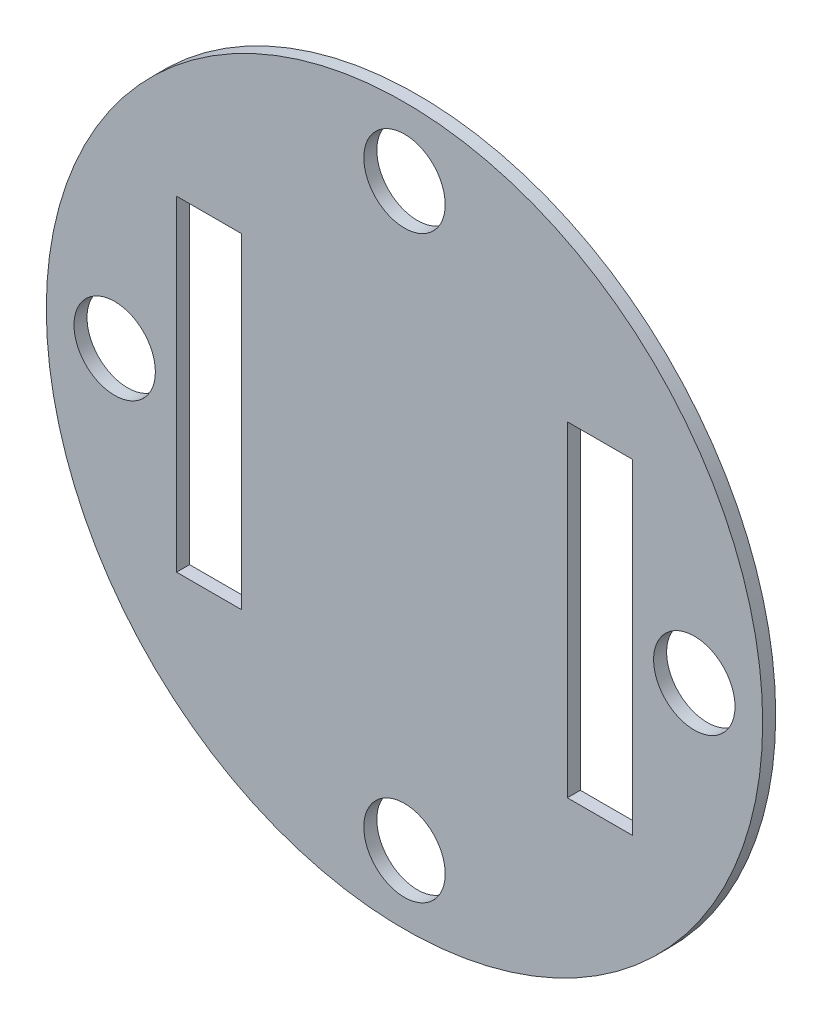
from build123d import *

# Parameters (mm, degrees)
SKETCH4_R           = 59
BOSS_EXTRUDE3_DEPTH = 2
SKETCH5_R           = 1.375
BOSS_EXTRUDE5_DEPTH = 7
SKETCH8_R           = 2.375
BOSS_EXTRUDE6_DEPTH = 2
BOSS_EXTRUDE7_DEPTH = 18
SKETCH10_R          = 7.5
CUT_EXTRUDE1_DEPTH  = 18
SKETCH12_R          = 57.5
CUT_EXTRUDE2_DEPTH  = 5
CUT_EXTRUDE3_DEPTH  = 5.5
SKETCH15_R          = 89.714021058
SKETCH15_R_2        = 57
CUT_EXTRUDE4_DEPTH  = 22
SKETCH16_R          = 62.462022857
CUT_EXTRUDE8_DEPTH  = 52
CUT_EXTRUDE9_DEPTH  = 52
SKETCH18_R          = 80.62246508
SKETCH18_R_2        = 55
CUT_EXTRUDE10_DEPTH = 10
SKETCH19_R          = 55
BOSS_EXTRUDE8_DEPTH = 2
SKETCH20_R          = 6.25
CUT_EXTRUDE11_DEPTH = 2
SKETCH21_W          = 10
SKETCH21_H          = 50
CUT_EXTRUDE12_DEPTH = 3
SKETCH22_R          = 40.394642533
CUT_EXTRUDE13_DEPTH = 10


with BuildPart() as part:
    # Sketch4 → Boss-Extrude3 (new body)
    with BuildSketch(Plane.XY):
        Circle(SKETCH4_R)
    extrude(amount=BOSS_EXTRUDE3_DEPTH)

    # Sketch5 → Boss-Extrude5 (add)
    with BuildSketch(Plane.XY.offset(2)):
        with Locations((-22.5, 27.5)):
            Circle(SKETCH5_R)
        with Locations((22.5, 27.5)):
            Circle(SKETCH5_R)
        with Locations((22.5, -27.5)):
            Circle(SKETCH5_R)
        with Locations((-22.5, -27.5)):
            Circle(SKETCH5_R)
    extrude(amount=BOSS_EXTRUDE5_DEPTH)

    # Sketch8 → Boss-Extrude6 (add)
    with BuildSketch(Plane.XY.offset(2)):
        with Locations((-22.5, 27.5)):
            Circle(SKETCH8_R)
        with Locations((22.5, 27.5)):
            Circle(SKETCH8_R)
        with Locations((-22.5, -27.5)):
            Circle(SKETCH8_R)
        with Locations((22.5, -27.5)):
            Circle(SKETCH8_R)
    extrude(amount=BOSS_EXTRUDE6_DEPTH)

    # Sketch9 → Boss-Extrude7 (add)
    with BuildSketch(Plane.XY.offset(2)):
        with BuildLine():
            ThreePointArc((-4.745762712, 55.798546005), (0, 56), (4.745762712, 55.798546005))
            Line((4.745762712, 55.798546005), (5, 58.787753827))
            ThreePointArc((5, 58.787753827), (0, 59), (-5, 58.787753827))
            Line((-5, 58.787753827), (-4.745762712, 55.798546005))
        make_face()
        with BuildLine():
            Line((-55.798546005, 4.745762712), (-58.787753827, 5))
            ThreePointArc((-58.787753827, 5), (-59, 0), (-58.787753827, -5))
            Line((-58.787753827, -5), (-55.798546005, -4.745762712))
            ThreePointArc((-55.798546005, -4.745762712), (-56, 0), (-55.798546005, 4.745762712))
        make_face()
        with BuildLine():
            ThreePointArc((58.787753827, -5), (59, 0), (58.787753827, 5))
            Line((58.787753827, 5), (55.798546005, 4.745762712))
            ThreePointArc((55.798546005, 4.745762712), (56, 0), (55.798546005, -4.745762712))
            Line((55.798546005, -4.745762712), (58.787753827, -5))
        make_face()
        with BuildLine():
            ThreePointArc((-4.745762712, -55.798546005), (0, -56), (4.745762712, -55.798546005))
            Line((4.745762712, -55.798546005), (5, -58.787753827))
            ThreePointArc((5, -58.787753827), (0, -59), (-5, -58.787753827))
            Line((-5, -58.787753827), (-4.745762712, -55.798546005))
        make_face()
    extrude(amount=BOSS_EXTRUDE7_DEPTH)

    # Sketch10 → Cut-Extrude1 (cut)
    with BuildSketch(Plane.XY.offset(2)):
        with Locations((-40, 0)):
            Circle(SKETCH10_R)
    extrude(amount=-CUT_EXTRUDE1_DEPTH, mode=Mode.SUBTRACT)

    # Sketch12 → Cut-Extrude2 (cut)
    with BuildSketch(Plane.XY.offset(20)):
        Circle(SKETCH12_R)
    extrude(amount=-CUT_EXTRUDE2_DEPTH, mode=Mode.SUBTRACT)

    # Sketch13 → Cut-Extrude3 (cut)
    with BuildSketch(Plane(origin=(0, 0, 0), x_dir=(-1, 0, 0), z_dir=(0, 0, -1))):
        with BuildLine():
            Line((-57.243329786, 4.868644068), (-58.787753827, 5))
            ThreePointArc((-58.787753827, 5), (-59, 0), (-58.787753827, -5))
            Line((-58.787753827, -5), (-57.243329786, -4.868644068))
            ThreePointArc((-57.243329786, -4.868644068), (-57.45, 0), (-57.243329786, 4.868644068))
        make_face()
        with BuildLine():
            ThreePointArc((5, 58.787753827), (0, 59), (-5, 58.787753827))
            Line((-5, 58.787753827), (-4.868644068, 57.243329786))
            ThreePointArc((-4.868644068, 57.243329786), (0, 57.45), (4.868644068, 57.243329786))
            Line((4.868644068, 57.243329786), (5, 58.787753827))
        make_face()
        with BuildLine():
            Line((-4.868644068, -57.243329786), (-5, -58.787753827))
            ThreePointArc((-5, -58.787753827), (0, -59), (5, -58.787753827))
            Line((5, -58.787753827), (4.868644068, -57.243329786))
            ThreePointArc((4.868644068, -57.243329786), (0, -57.45), (-4.868644068, -57.243329786))
        make_face()
        with BuildLine():
            ThreePointArc((58.787753827, -5), (59, 0), (58.787753827, 5))
            Line((58.787753827, 5), (57.243329786, 4.868644068))
            ThreePointArc((57.243329786, 4.868644068), (57.45, 0), (57.243329786, -4.868644068))
            Line((57.243329786, -4.868644068), (58.787753827, -5))
        make_face()
    extrude(amount=-CUT_EXTRUDE3_DEPTH, mode=Mode.SUBTRACT)

    # Sketch15 → Cut-Extrude4 (cut)
    with BuildSketch(Plane(origin=(0, 0, 0), x_dir=(-1, 0, 0), z_dir=(0, 0, -1))):
        Circle(SKETCH15_R)
        Circle(SKETCH15_R_2, mode=Mode.SUBTRACT)
    extrude(amount=-CUT_EXTRUDE4_DEPTH, mode=Mode.SUBTRACT)

    # Sketch16 → Cut-Extrude8 (cut)
    with BuildSketch(Plane.XY.offset(2)):
        Circle(SKETCH16_R)
        with BuildLine():
            Line((55.798546005, 4.745762712), (56.794948612, 4.830508475))
            ThreePointArc((56.794948612, 4.830508475), (40.305086528, 40.305086528), (4.830508475, 56.794948612))
            Line((4.830508475, 56.794948612), (4.745762712, 55.798546005))
            ThreePointArc((4.745762712, 55.798546005), (0, 56), (-4.745762712, 55.798546005))
            Line((-4.745762712, 55.798546005), (-4.830508475, 56.794948612))
            ThreePointArc((-4.830508475, 56.794948612), (-40.305086528, 40.305086528), (-56.794948612, 4.830508475))
            Line((-56.794948612, 4.830508475), (-55.798546005, 4.745762712))
            ThreePointArc((-55.798546005, 4.745762712), (-56, 0), (-55.798546005, -4.745762712))
            Line((-55.798546005, -4.745762712), (-56.794948612, -4.830508475))
            ThreePointArc((-56.794948612, -4.830508475), (-40.305086528, -40.305086528), (-4.830508475, -56.794948612))
            Line((-4.830508475, -56.794948612), (-4.745762712, -55.798546005))
            ThreePointArc((-4.745762712, -55.798546005), (0, -56), (4.745762712, -55.798546005))
            Line((4.745762712, -55.798546005), (4.830508475, -56.794948612))
            ThreePointArc((4.830508475, -56.794948612), (40.305086528, -40.305086528), (56.794948612, -4.830508475))
            Line((56.794948612, -4.830508475), (55.798546005, -4.745762712))
            ThreePointArc((55.798546005, -4.745762712), (56, 0), (55.798546005, 4.745762712))
        make_face(mode=Mode.SUBTRACT)
    extrude(amount=CUT_EXTRUDE8_DEPTH, mode=Mode.SUBTRACT)

    # Sketch17 → Cut-Extrude9 (cut)
    with BuildSketch(Plane.XY.offset(2)):
        with BuildLine():
            Line((-5, 57), (5, 57))
            Line((5, 57), (4.806106124, 54.789609817))
            ThreePointArc((4.806106124, 54.789609817), (0, 55), (-4.806106124, 54.789609817))
            Line((-4.806106124, 54.789609817), (-5, 57))
        make_face()
        with BuildLine():
            Line((54.789609817, 4.806106124), (57, 5))
            Line((57, 5), (57, -5))
            Line((57, -5), (54.789609817, -4.806106124))
            ThreePointArc((54.789609817, -4.806106124), (55, 0), (54.789609817, 4.806106124))
        make_face()
        with BuildLine():
            Line((4.806106124, -54.789609817), (5, -57))
            Line((5, -57), (-5, -57))
            Line((-5, -57), (-4.806106124, -54.789609817))
            ThreePointArc((-4.806106124, -54.789609817), (0, -55), (4.806106124, -54.789609817))
        make_face()
        with BuildLine():
            Line((-54.789609817, -4.806106124), (-57, -5))
            Line((-57, -5), (-57, 5))
            Line((-57, 5), (-54.789609817, 4.806106124))
            ThreePointArc((-54.789609817, 4.806106124), (-55, 0), (-54.789609817, -4.806106124))
        make_face()
    extrude(amount=-CUT_EXTRUDE9_DEPTH, mode=Mode.SUBTRACT)

    # Sketch18 → Cut-Extrude10 (cut)
    with BuildSketch(Plane.XY.offset(2)):
        Circle(SKETCH18_R)
        Circle(SKETCH18_R_2, mode=Mode.SUBTRACT)
    extrude(amount=-CUT_EXTRUDE10_DEPTH, mode=Mode.SUBTRACT)

    # Sketch19 → Boss-Extrude8 (add)
    with BuildSketch(Plane.XY.offset(2)):
        Circle(SKETCH19_R)
    extrude(amount=-BOSS_EXTRUDE8_DEPTH)

    # Sketch20 → Cut-Extrude11 (cut)
    with BuildSketch(Plane.XY.offset(2)):
        with Locations((0, 44.5)):
            Circle(SKETCH20_R)
        with Locations((44.5, 0)):
            Circle(SKETCH20_R)
        with Locations((0, -44.5)):
            Circle(SKETCH20_R)
        with Locations((-44.5, 0)):
            Circle(SKETCH20_R)
    extrude(amount=-CUT_EXTRUDE11_DEPTH, mode=Mode.SUBTRACT)

    # Sketch21 → Cut-Extrude12 (cut)
    with BuildSketch(Plane.XY.offset(2)):
        with Locations((30, 0)):
            Rectangle(SKETCH21_W, SKETCH21_H)
        with Locations((-30, 0)):
            Rectangle(SKETCH21_W, SKETCH21_H)
    extrude(amount=-CUT_EXTRUDE12_DEPTH, mode=Mode.SUBTRACT)

    # Sketch22 → Cut-Extrude13 (cut)
    with BuildSketch(Plane.XY.offset(2)):
        Circle(SKETCH22_R)
    extrude(amount=CUT_EXTRUDE13_DEPTH, mode=Mode.SUBTRACT)


solid = part.part
